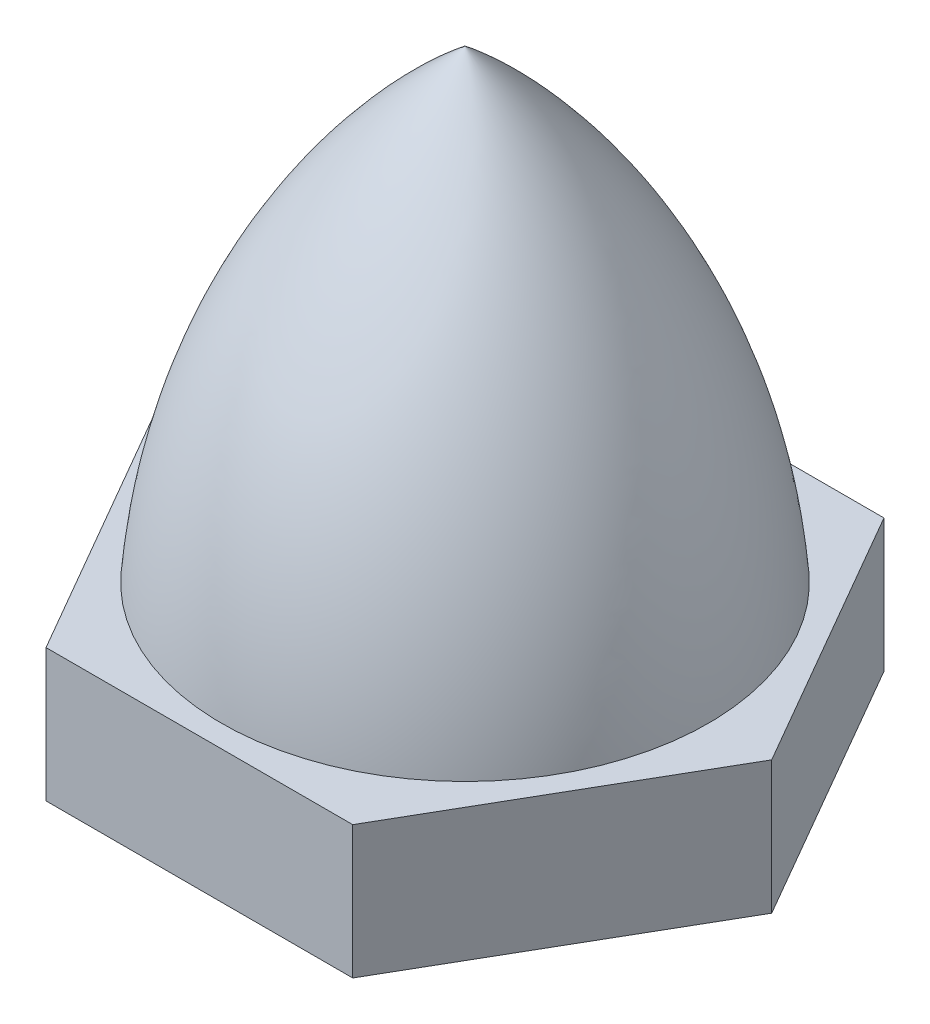
from build123d import *

# Parameters (mm, degrees)
Y_KSEKLIK_EKSTR_ZYON1_DEPTH = 3
IZIM3_R                     = 2.5
KES_EKSTR_ZYON1_DEPTH       = 10.5


with BuildPart() as part:
    # Çizim1 → Döndür1 (revolve)
    with BuildSketch(Plane.XY):
        with BuildLine():
            Line((11.078966003, 25.398614276), (11.078966003, 14.898614276))
            Line((11.078966003, 14.898614276), (16.578966003, 14.898614276))
            ThreePointArc((16.578966003, 14.898614276), (14.910111185, 20.714928419), (11.078966003, 25.398614276))
        make_face()
    revolve(axis=Axis((11.078966003, 25.398614276, 0), (0, -1, 0)))

    # Çizim2 → Yükseklik-Ekstrüzyon1 (add)
    with BuildSketch(Plane.XZ.offset(-14.898614276)):
        Polygon((14.543067618, 6), (7.614864387, 6), (4.150762772, 0), (7.614864387, -6), (14.543067618, -6), (18.007169233, 0), align=None)
    extrude(amount=Y_KSEKLIK_EKSTR_ZYON1_DEPTH)

    # Çizim3 → Kes-Ekstrüzyon1 (cut)
    with BuildSketch(Plane.XZ.offset(-11.898614276)):
        with Locations((11.078966003, 0)):
            Circle(IZIM3_R)
    extrude(amount=-KES_EKSTR_ZYON1_DEPTH, mode=Mode.SUBTRACT)


solid = part.part
